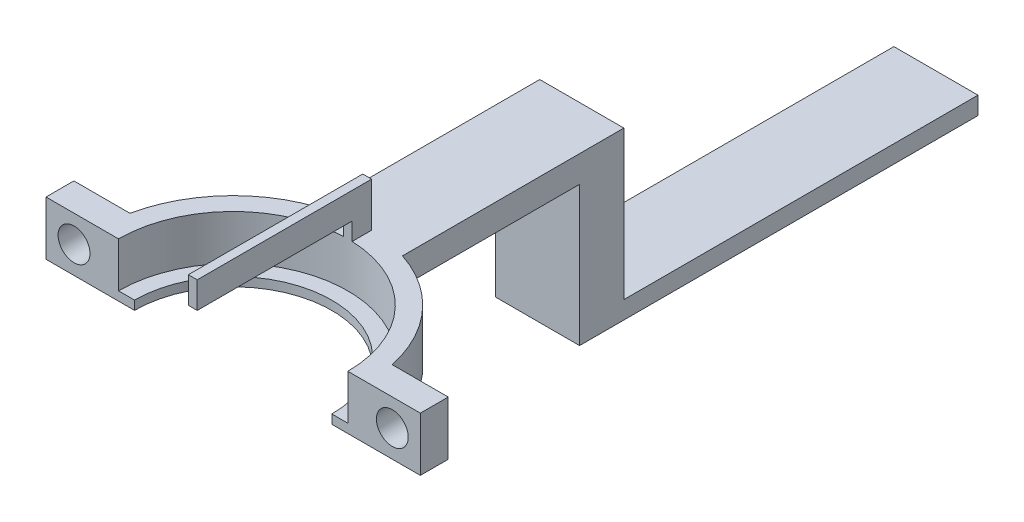
from build123d import *

# Parameters (mm, degrees)
BOSS_EXTRUDE1_DEPTH = 5
BOSS_EXTRUDE2_DEPTH = 3
BOSS_EXTRUDE3_DEPTH = 3
SKETCH10_W          = 9.5
SKETCH10_H          = 5
BOSS_EXTRUDE4_DEPTH = 15.78
SKETCH11_W          = 9.5
SKETCH11_H          = 2
BOSS_EXTRUDE5_DEPTH = 40
BOSS_EXTRUDE6_DEPTH = 6.09393
SKETCH14_R          = 1.8
CUT_EXTRUDE1_DEPTH  = 6.3
SKETCH15_W          = 51.153217575
SKETCH15_H          = 31.902182189
CUT_EXTRUDE3_DEPTH  = 19.78


with BuildPart() as part:
    # Sketch3 → Revolve1 (revolve)
    with BuildSketch(Plane.XY):
        Polygon((-62.694264441, 10.250679103), (-62.694264441, 11.733728816), (-64.884531744, 11.733728816), (-64.884531744, 5.639799249), (-60.884531744, 5.639799249), (-60.884531744, 6.650679103), (-62.694264441, 6.650679103), align=None)
    revolve(axis=Axis((-49.744264441, 0, 0), (0, 1, 0)))

    # Sketch7 → Boss-Extrude1 (add)
    with BuildSketch(Plane(origin=(0, 11.733728816, 0), x_dir=(1, 0, 0), z_dir=(0, 1, 0))):
        with BuildLine():
            Line((-50.244264441, 15.132008921), (-50.244264441, 12.94034389))
            ThreePointArc((-50.244264441, 12.94034389), (-49.744264441, 12.95), (-49.244264441, 12.94034389))
            Line((-49.244264441, 12.94034389), (-49.244264441, 15.132008921))
            ThreePointArc((-49.244264441, 15.132008921), (-49.744264441, 15.140267302), (-50.244264441, 15.132008921))
        make_face()
    extrude(amount=BOSS_EXTRUDE1_DEPTH)

    # Sketch8 → Boss-Extrude2 (add)
    with BuildSketch(Plane(origin=(0, 16.733728816, 0), x_dir=(1, 0, 0), z_dir=(0, 1, 0))):
        with BuildLine():
            Line((-50.244264441, 15.132008921), (-50.244264441, 12.94034389))
            Line((-50.244264441, 12.94034389), (-50.244264441, -4.55965611))
            Line((-50.244264441, -4.55965611), (-49.244264441, -4.55965611))
            Line((-49.244264441, -4.55965611), (-49.244264441, 12.94034389))
            Line((-49.244264441, 12.94034389), (-49.244264441, 15.132008921))
            ThreePointArc((-49.244264441, 15.132008921), (-49.744264441, 15.140267302), (-50.244264441, 15.132008921))
        make_face()
    extrude(amount=-BOSS_EXTRUDE2_DEPTH)

    # Sketch9 → Boss-Extrude3 (add)
    with BuildSketch(Plane(origin=(0, 11.733728816, 0), x_dir=(1, 0, 0), z_dir=(0, 1, 0))):
        with BuildLine():
            Line((-54.494264441, 14.375854548), (-54.494264441, 39.375854548))
            Line((-54.494264441, 39.375854548), (-44.994264441, 39.375854548))
            Line((-44.994264441, 39.375854548), (-44.994264441, 14.375854548))
            ThreePointArc((-44.994264441, 14.375854548), (-47.092177082, 14.906177465), (-49.244264441, 15.132008921))
            ThreePointArc((-49.244264441, 15.132008921), (-49.744264441, 15.140267302), (-50.244264441, 15.132008921))
            ThreePointArc((-50.244264441, 15.132008921), (-52.3963518, 14.906177465), (-54.494264441, 14.375854548))
        make_face()
    extrude(amount=-BOSS_EXTRUDE3_DEPTH)

    # Sketch10 → Boss-Extrude4 (add)
    with BuildSketch(Plane.XZ.offset(-8.733728816)):
        with Locations((-49.744264441, -36.875854548)):
            Rectangle(SKETCH10_W, SKETCH10_H)
    extrude(amount=BOSS_EXTRUDE4_DEPTH)

    # Sketch11 → Boss-Extrude5 (add)
    with BuildSketch(Plane(origin=(0, 0, -39.375854548), x_dir=(-1, 0, 0), z_dir=(0, 0, -1))):
        with Locations((49.744264441, -6.046271184)):
            Rectangle(SKETCH11_W, SKETCH11_H)
    extrude(amount=BOSS_EXTRUDE5_DEPTH)

    # Sketch13 → Boss-Extrude6 (add)
    with BuildSketch(Plane(origin=(0, 11.733728816, 0), x_dir=(1, 0, 0), z_dir=(0, 1, 0))):
        with BuildLine():
            Line((-28.603997139, 3.15), (-34.935307895, 3.15))
            ThreePointArc((-34.935307895, 3.15), (-34.603997139, 0), (-34.935307895, -3.15))
            Line((-34.935307895, -3.15), (-28.603997139, -3.15))
            Line((-28.603997139, -3.15), (-28.603997139, 3.15))
        make_face()
        with BuildLine():
            Line((-70.884531744, 3.15), (-70.884531744, -3.15))
            Line((-70.884531744, -3.15), (-64.553220987, -3.15))
            ThreePointArc((-64.553220987, -3.15), (-64.884531744, 0), (-64.553220987, 3.15))
            Line((-64.553220987, 3.15), (-70.884531744, 3.15))
        make_face()
    extrude(amount=-BOSS_EXTRUDE6_DEPTH)

    # Sketch14 → Cut-Extrude1 (cut)
    with BuildSketch(Plane.XY.offset(3.15)):
        with Locations((-31.769652517, 8.686764033)):
            Circle(SKETCH14_R)
        with Locations((-67.718876365, 8.686764033)):
            Circle(SKETCH14_R)
    extrude(amount=-CUT_EXTRUDE1_DEPTH, mode=Mode.SUBTRACT)

    # Sketch15 → Cut-Extrude3 (cut, through all)
    with BuildSketch(Plane(origin=(0, 11.733728816, 0), x_dir=(1, 0, 0), z_dir=(0, 1, 0))):
        with Locations((-49.018725857, -15.951091095)):
            Rectangle(SKETCH15_W, SKETCH15_H)
    extrude(amount=-CUT_EXTRUDE3_DEPTH, mode=Mode.SUBTRACT)


solid = part.part
